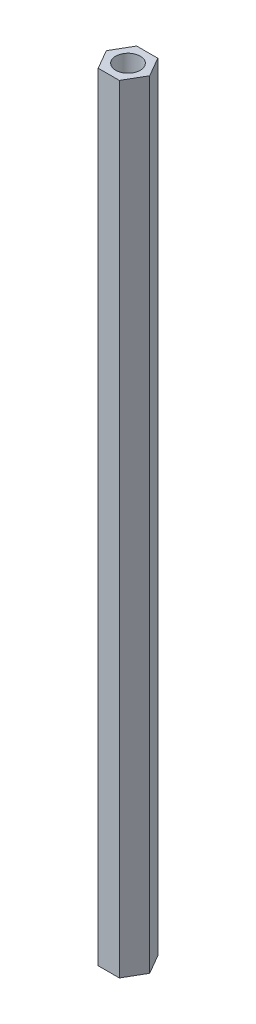
from build123d import *

# Parameters (mm, degrees)
SKETCH_1_R      = 1.5
EXTRUDE_1_DEPTH = 95


with BuildPart() as part:
    # 草图1 → 凸台-拉伸1 (new body)
    with BuildSketch(Plane(origin=(0, 0, 0), x_dir=(1, 0, 0), z_dir=(0, 1, 0))):
        Polygon((1.293226867, 2.35), (-1.293226867, 2.35), (-2.65, 0), (-1.293226867, -2.35), (1.293226867, -2.35), (2.65, 0), align=None)
        Circle(SKETCH_1_R, mode=Mode.SUBTRACT)
    extrude(amount=EXTRUDE_1_DEPTH)


solid = part.part
